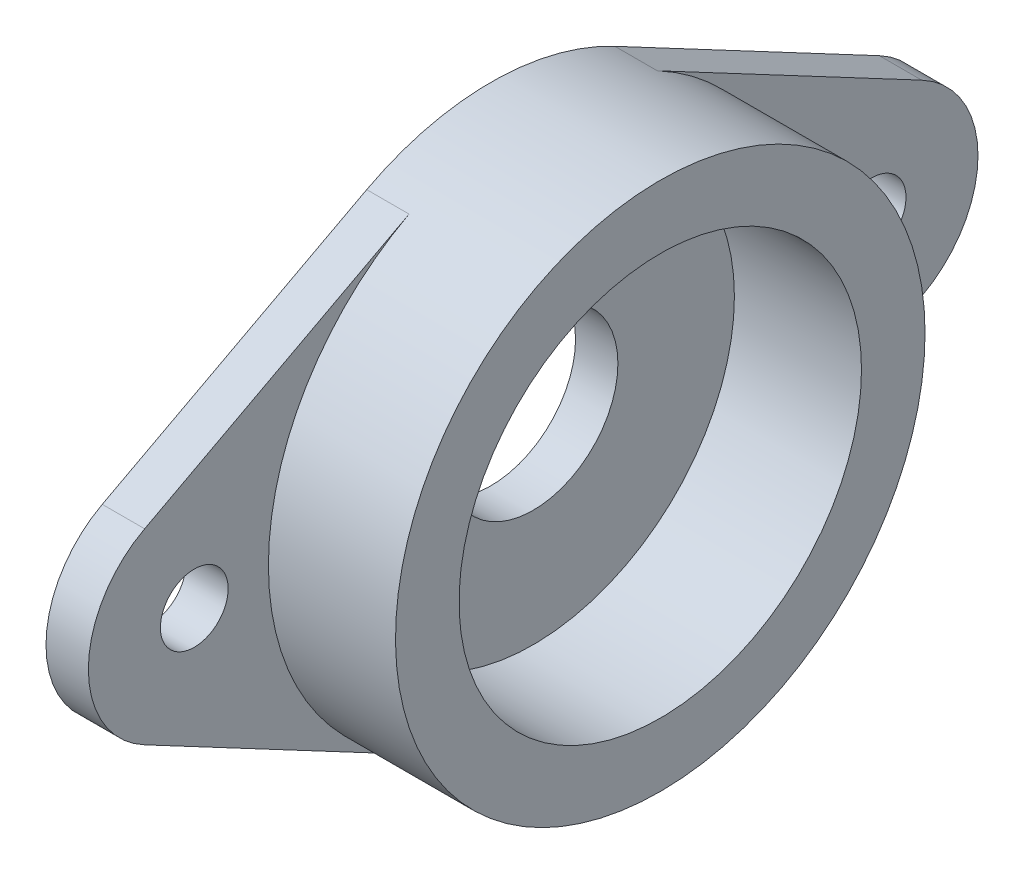
from build123d import *

# Parameters (mm, degrees)
SKETCH1_R             = 1.6
BOSS_EXTRUDE1_DEPTH   = 2
BOSS_EXTRUDE1_2_DEPTH = 2
SKETCH1_5_R           = 12.5
SKETCH1_5_R_2         = 9.5
BOSS_EXTRUDE2_DEPTH   = 8
SKETCH1_6_R           = 9.5
SKETCH1_6_R_2         = 4
BOSS_EXTRUDE3_DEPTH   = 2


with BuildPart() as part:
    # Sketch1 → Boss-Extrude1 (new body)
    with BuildSketch(Plane(origin=(0, 0, 0), x_dir=(0, 0, -1), z_dir=(1, 0, 0))):
        with BuildLine():
            Line((-5.859375, 11.041635957), (-18.34375, 4.416654383))
            ThreePointArc((-18.34375, 4.416654383), (-21, 0), (-18.34375, -4.416654383))
            Line((-18.34375, -4.416654383), (-5.859375, -11.041635957))
            ThreePointArc((-5.859375, -11.041635957), (-12.5, 0), (-5.859375, 11.041635957))
        make_face()
        with Locations((-16, 0)):
            Circle(SKETCH1_R, mode=Mode.SUBTRACT)
    extrude(amount=BOSS_EXTRUDE1_DEPTH)



with BuildPart() as body_2:
    # Sketch1 → Boss-Extrude1 2 (new body)
    with BuildSketch(Plane(origin=(0, 0, 0), x_dir=(0, 0, -1), z_dir=(1, 0, 0))):
        with BuildLine():
            Line((18.34375, 4.416654383), (5.859375, 11.041635957))
            ThreePointArc((5.859375, 11.041635957), (10.711960313, 6.44235254), (12.5, 0))
            ThreePointArc((12.5, 0), (10.711960313, -6.44235254), (5.859375, -11.041635957))
            Line((5.859375, -11.041635957), (18.34375, -4.416654383))
            ThreePointArc((18.34375, -4.416654383), (21, 0), (18.34375, 4.416654383))
        make_face()
        with Locations((16, 0)):
            Circle(SKETCH1_R, mode=Mode.SUBTRACT)
    extrude(amount=BOSS_EXTRUDE1_2_DEPTH)


with BuildPart() as part_1:
    add(part.part)

    add(body_2.part)  # Boss-Extrude2 merges body 2
    # Sketch1_5 → Boss-Extrude2 (add)
    with BuildSketch(Plane(origin=(0, 0, 0), x_dir=(0, 0, -1), z_dir=(1, 0, 0))):
        Circle(SKETCH1_5_R)
        Circle(SKETCH1_5_R_2, mode=Mode.SUBTRACT)
    extrude(amount=BOSS_EXTRUDE2_DEPTH)

    # Sketch1_6 → Boss-Extrude3 (add)
    with BuildSketch(Plane(origin=(0, 0, 0), x_dir=(0, 0, -1), z_dir=(1, 0, 0))):
        Circle(SKETCH1_6_R)
        Circle(SKETCH1_6_R_2, mode=Mode.SUBTRACT)
    extrude(amount=BOSS_EXTRUDE3_DEPTH)


solid = part_1.part
